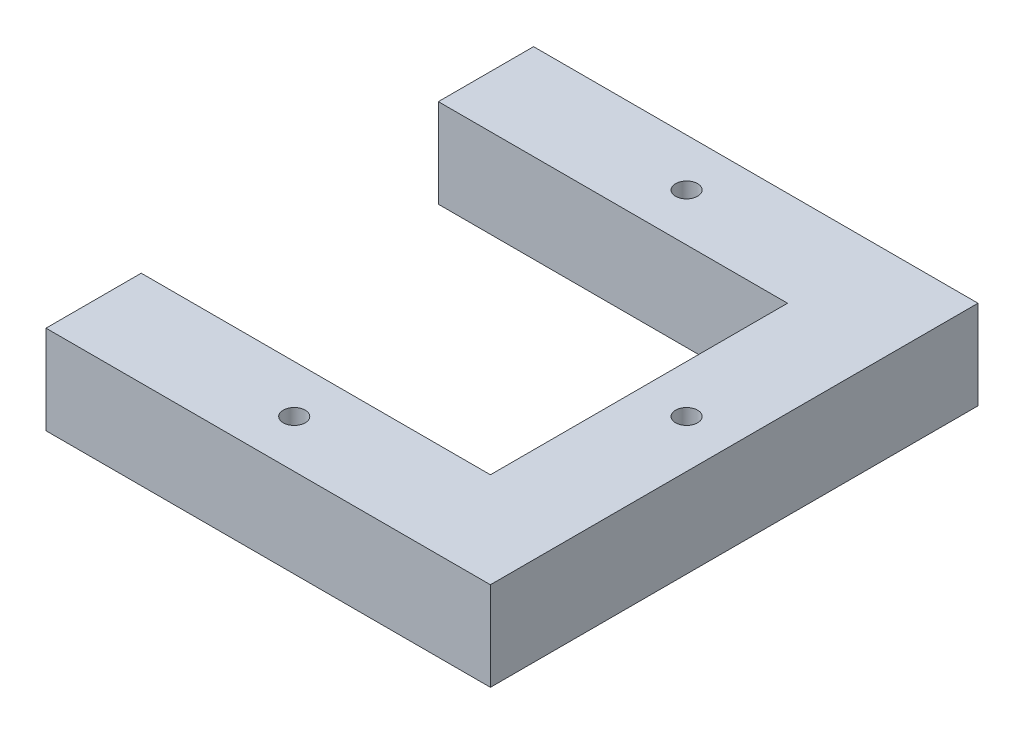
from build123d import *

# Parameters (mm, degrees)
SKETCH1_R           = 4.399999963
BOSS_EXTRUDE1_DEPTH = 35.56


with BuildPart() as part:
    # Sketch1 → Boss-Extrude1 (new body)
    with BuildSketch(Plane(origin=(0, 0, 0), x_dir=(1, 0, 0), z_dir=(0, 1, 0))):
        Polygon((-80.261100082, 59.438899918), (-80.261100082, 97.538899918), (97.538899918, 97.538899918), (97.538899918, -97.538899918), (-80.261100082, -97.538899918), (-80.261100082, -59.438899918), (59.438899918, -59.438899918), (59.438899918, 59.438899918), align=None)
        with Locations((0, 78.488899918)):
            Circle(SKETCH1_R, mode=Mode.SUBTRACT)
        with Locations((0, -78.488899918)):
            Circle(SKETCH1_R, mode=Mode.SUBTRACT)
        with Locations((78.488899918, 0)):
            Circle(SKETCH1_R, mode=Mode.SUBTRACT)
    extrude(amount=BOSS_EXTRUDE1_DEPTH)


solid = part.part
